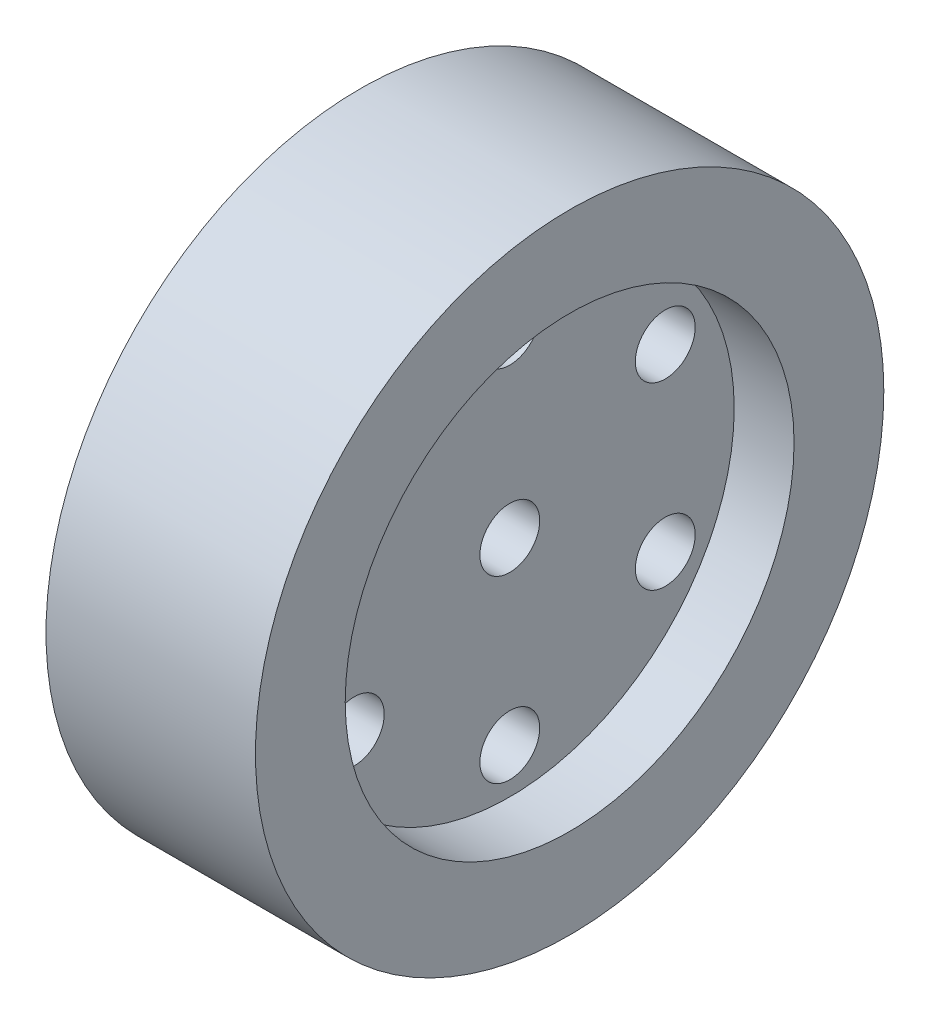
from build123d import *

# Parameters (mm, degrees)
SKETCH1_R           = 10.5
BOSS_EXTRUDE1_DEPTH = 7
SKETCH2_R           = 7.5
CUT_EXTRUDE1_DEPTH  = 2
SKETCH3_R           = 1
CUT_EXTRUDE2_DEPTH  = 6
SKETCH4_R           = 9.5
SKETCH4_R_2         = 2.5
CUT_EXTRUDE3_DEPTH  = 2


with BuildPart() as part:
    # Sketch1 → Boss-Extrude1 (new body)
    with BuildSketch(Plane(origin=(0, 0, 0), x_dir=(0, 0, -1), z_dir=(1, 0, 0))):
        Circle(SKETCH1_R)
    extrude(amount=BOSS_EXTRUDE1_DEPTH)

    # Sketch2 → Cut-Extrude1 (cut)
    with BuildSketch(Plane(origin=(7, 0, 0), x_dir=(0, 0, -1), z_dir=(1, 0, 0))):
        Circle(SKETCH2_R)
    extrude(amount=-CUT_EXTRUDE1_DEPTH, mode=Mode.SUBTRACT)

    # Sketch3 → Cut-Extrude2 (cut, through all)
    with BuildSketch(Plane(origin=(5, 0, 0), x_dir=(0, 0, -1), z_dir=(1, 0, 0))):
        with Locations((0, 6)):
            Circle(SKETCH3_R)
        Circle(SKETCH3_R)
        with Locations((5.196152423, 3)):
            Circle(SKETCH3_R)
        with Locations((5.196152423, -3)):
            Circle(SKETCH3_R)
        with Locations((0, -6)):
            Circle(SKETCH3_R)
        with Locations((-5.196152423, -3)):
            Circle(SKETCH3_R)
        with Locations((-5.196152423, 3)):
            Circle(SKETCH3_R)
    extrude(amount=-CUT_EXTRUDE2_DEPTH, mode=Mode.SUBTRACT)

    # Sketch4 → Cut-Extrude3 (cut)
    with BuildSketch(Plane.ZY):
        Circle(SKETCH4_R)
        Circle(SKETCH4_R_2, mode=Mode.SUBTRACT)
    extrude(amount=-CUT_EXTRUDE3_DEPTH, mode=Mode.SUBTRACT)


solid = part.part
